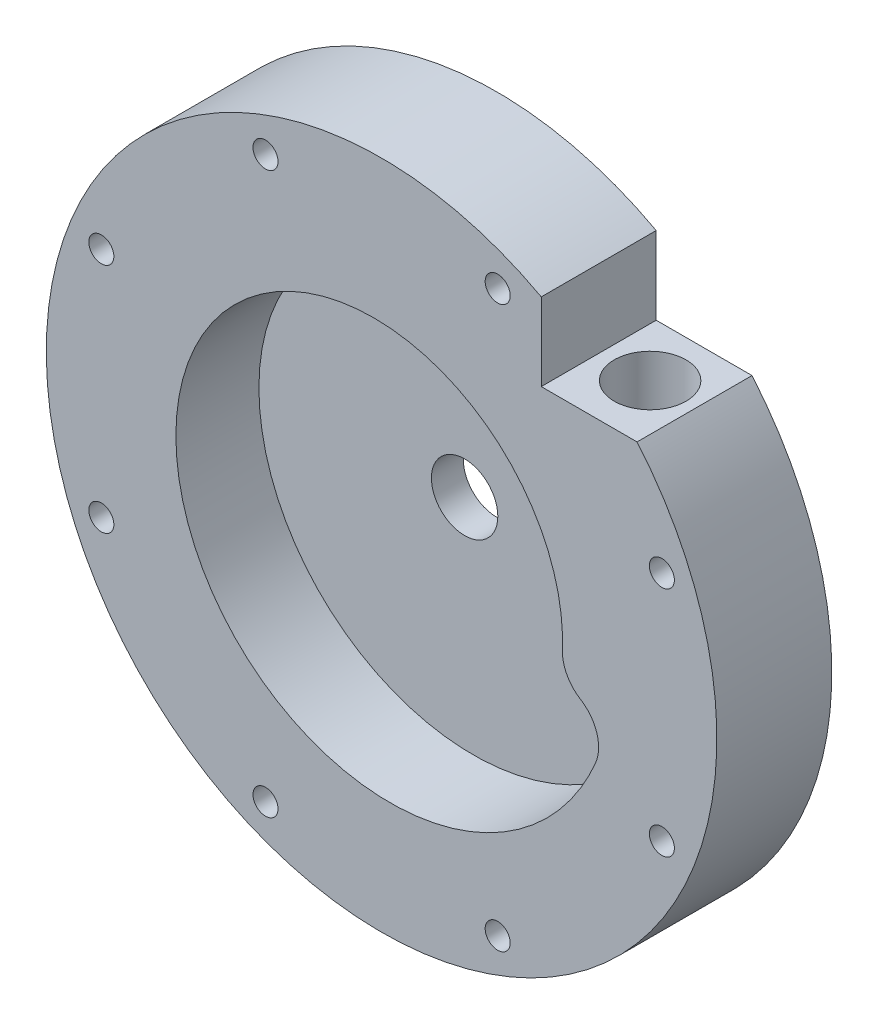
from build123d import *

# Parameters (mm, degrees)
SKETCH23_R            = 25.4
VOLUTE_CUT_DEPTH      = 17.51
SKETCH28_W            = 19.053968595
SKETCH28_H            = 15.450138368
OUTLET_HOLE_CUT_DEPTH = 23.86
OUTLET_HOLE_D         = 9.8044
OUTLET_HOLE_DEPTH     = 55.88
OUTLET_HOLE_TIP       = 2.945538927
OUTLET_NPT_D          = 14.2748
OUTLET_NPT_DEPTH      = 12.7
OUTLET_NPT_TIP        = 4.288582582
FASTENER_HOLES_D      = 4.9784
CIRPATTERN1_COUNT     = 8


with BuildPart() as part:
    # Sketch22 → Main Body (revolve)
    with BuildSketch(Plane(origin=(0, 0, 0), x_dir=(1, 0, 0), z_dir=(0, 1, 0))):
        Polygon((-25.4, 0), (-6.604, 0), (-6.604, 6.35), (-11.1125, 6.35), (-11.1125, 3.175), (-17.4625, 3.175), (-17.4625, 6.35), (-66.675, 6.35), (-66.675, -16.51), (-25.4, -16.51), align=None)
    revolve(axis=Axis((0, 0, 0), (0, 0, -1)))

    # Sketch23 → Volute Cut (cut, through all)
    with BuildSketch(Plane.XY):
        with BuildLine():
            ThreePointArc((42.554027377, -16.231646763), (42.805320101, -10.94498561), (39.552581276, -6.769865934))
            ThreePointArc((39.552581276, -6.769865934), (36.836858206, -3.87137787), (35.948703812, 0))
            add(Edge.make_bspline(
                [(35.948703812, 0), (35.9515816, 0.07538119), (35.957337916, 0.226162951), (35.964207937, 0.452426553), (35.969771157, 0.678783022), (35.978029534, 1.131847853), (35.980843708, 2.190601907), (35.920311441, 3.779931016), (35.747323363, 5.668216834), (35.489928088, 7.474298946), (35.141459932, 9.268877369), (34.702390603, 11.047358984), (34.17343386, 12.80516853), (33.555538624, 14.537761538), (32.849887572, 16.240636382), (32.057893687, 17.909346365), (31.181197352, 19.53951152), (30.221662701, 21.126830276), (29.181373626, 22.667090912), (28.062629225, 24.156182809), (26.867938753, 25.590107465), (25.60001603, 26.964989265), (24.261773335, 28.277085961), (22.856314773, 29.522798851), (21.386929147, 30.698682629), (19.85708232, 31.801454876), (18.270409111, 32.828005175), (16.630704717, 33.775403815), (14.941915703, 34.640910073), (13.208130556, 35.421980041), (11.43356985, 36.116273987), (9.622576022, 36.721663214), (7.779602801, 37.236236415), (5.909204301, 37.658305492), (4.016023818, 37.986410831), (2.104782347, 38.219326014), (0.180266852, 38.356061949), (-1.75268168, 38.395870413), (-3.689180377, 38.338246992), (-5.624316777, 38.182933409), (-7.553161251, 37.929919231), (-9.470779522, 37.579442948), (-11.37224525, 37.131992419), (-13.252652651, 36.588304682), (-15.107129112, 35.949365124), (-16.930847778, 35.216406011), (-18.719040078, 34.390904381), (-20.467008144, 33.474579298), (-22.170137115, 32.469388481), (-23.823907266, 31.377524301), (-25.42390596, 30.201409162), (-26.965839357, 28.943690275), (-28.445543888, 27.607233836), (-29.858997424, 26.195118613), (-31.202330147, 24.710628968), (-32.471835063, 23.157247319), (-33.663978152, 21.538646066), (-34.775408104, 19.858679), (-35.802965645, 18.121372202), (-36.743692396, 16.330914471), (-37.594839261, 14.491647299), (-38.353874308, 12.608054401), (-39.018490139, 10.68475085), (-39.586610697, 8.726471825), (-40.056397525, 6.738061006), (-40.426255434, 4.724458642), (-40.694837576, 2.690689328), (-40.861049894, 0.641849508), (-40.924054953, -1.416905249), (-40.883275123, -3.480373184), (-40.738395114, -5.543319447), (-40.489363842, -7.600489337), (-40.13639564, -9.646621653), (-39.679970776, -11.676462103), (-39.120835312, -13.684776759), (-38.460000265, -15.666365517), (-37.698740094, -17.61607551), (-36.838590511, -19.528814477), (-35.881345602, -21.399564006), (-34.829054288, -23.223392663), (-33.684016107, -24.995468936), (-32.44877635, -26.711073982), (-31.126120537, -28.365614138), (-29.719068263, -29.954633155), (-28.230866416, -31.473824138), (-26.664981791, -32.919041144), (-25.025093105, -34.286310417), (-23.315082441, -35.571841228), (-21.53902614, -36.772036288), (-19.701185153, -37.883501708), (-17.805994889, -38.903056478), (-15.85805457, -39.827741435), (-13.862116128, -40.654827709), (-11.823072667, -41.381824596), (-9.745946518, -42.006486871), (-7.635876912, -42.526821485), (-5.498107312, -42.941093656), (-3.337972426, -43.247832311), (-1.160884928, -43.445834888), (1.027678058, -43.534171454), (3.222188708, -43.512188152), (5.417082419, -43.379509955), (7.606771886, -43.136042707), (9.785661288, -42.781974466), (11.948160555, -42.317776118), (14.08869967, -41.74420128), (16.201742982, -41.062285471), (18.281803484, -40.273344558), (20.323457017, -39.378972487), (22.321356376, -38.381038284), (24.27024527, -37.281682345), (26.164972102, -36.083312015), (28.000503535, -34.788596469), (29.77193781, -33.400460899), (31.474517775, -31.92208003), (33.103643596, -30.356870964), (34.654885111, -28.708485383), (36.123993806, -26.980801118), (37.506914359, -25.17791311), (38.799795742, -23.304123775), (39.999001844, -21.363932809), (41.101121576, -19.362026441), (41.938186302, -17.641904891), (42.402189205, -16.588613759), (42.554027377, -16.231646763)],
                knots=[0, 0, 0, 0, 0.000879209, 0.001758645, 0.002638305, 0.003518191, 0.007039982, 0.014977213, 0.022047939, 0.029133237, 0.036233164, 0.043347773, 0.050477114, 0.057621232, 0.06478017, 0.071953969, 0.079142669, 0.086346306, 0.093564916, 0.100798534, 0.108047194, 0.115310927, 0.122589766, 0.12988374, 0.13719288, 0.144517215, 0.151856774, 0.159211583, 0.16658167, 0.173967063, 0.181367786, 0.188783866, 0.196215328, 0.203662198, 0.211124498, 0.218602253, 0.226095488, 0.233604225, 0.241128486, 0.248668296, 0.256223676, 0.263794648, 0.271381234, 0.278983456, 0.286601335, 0.294234891, 0.301884146, 0.309549121, 0.317229835, 0.324926308, 0.332638561, 0.340366614, 0.348110485, 0.355870195, 0.363645762, 0.371437205, 0.379244543, 0.387067795, 0.39490698, 0.402762115, 0.410633219, 0.41852031, 0.426423405, 0.434342523, 0.442277682, 0.450228898, 0.458196189, 0.466179572, 0.474179065, 0.482194684, 0.490226447, 0.498274369, 0.506338468, 0.514418761, 0.522515263, 0.530627991, 0.538756962, 0.546902191, 0.555063694, 0.563241488, 0.571435588, 0.57964601, 0.58787277, 0.596115883, 0.604375364, 0.61265123, 0.620943495, 0.629252175, 0.637577285, 0.64591884, 0.654276855, 0.662651345, 0.671042324, 0.679449808, 0.687873812, 0.696314349, 0.704771435, 0.713245083, 0.721735309, 0.730242127, 0.738765551, 0.747305595, 0.755862273, 0.7644356, 0.77302559, 0.781632256, 0.790255613, 0.798895674, 0.807552454, 0.816225965, 0.824916222, 0.833623239, 0.842347028, 0.851087604, 0.859844979, 0.868619169, 0.877410184, 0.88621804, 0.895042749, 0.903884325, 0.912742781, 0.921618129, 0.930510383, 0.935031581, 0.935031581, 0.935031581, 0.935031581], degree=3))
        make_face()
        Circle(SKETCH23_R, mode=Mode.SUBTRACT)
    extrude(amount=VOLUTE_CUT_DEPTH, mode=Mode.SUBTRACT)

    # Sketch28 → Outlet Hole Cut (cut, through all)
    with BuildSketch(Plane.XY.offset(16.51)):
        with Locations((41.276984298, 50.905069184)):
            Rectangle(SKETCH28_W, SKETCH28_H)
    extrude(amount=-OUTLET_HOLE_CUT_DEPTH, mode=Mode.SUBTRACT)

    # Outlet Hole
    with Locations(Plane(origin=(41.529, 43.18, 4.637659), x_dir=(0, 0, 1), z_dir=(0, 1, 0))):
        with Locations((0, 0)):
            Hole(OUTLET_HOLE_D / 2, depth=OUTLET_HOLE_DEPTH)
            with Locations((0, 0, -(OUTLET_HOLE_DEPTH + OUTLET_HOLE_TIP / 2))):  # 118° drill point
                Cone(0, OUTLET_HOLE_D / 2, OUTLET_HOLE_TIP, mode=Mode.SUBTRACT)

    # Outlet NPT
    with Locations(Plane(origin=(41.529, 43.18, 4.637659), x_dir=(0, 0, 1), z_dir=(0, 1, 0))):
        with Locations((0, 0)):
            Hole(OUTLET_NPT_D / 2, depth=OUTLET_NPT_DEPTH)
            with Locations((0, 0, -(OUTLET_NPT_DEPTH + OUTLET_NPT_TIP / 2))):  # 118° drill point
                Cone(0, OUTLET_NPT_D / 2, OUTLET_NPT_TIP, mode=Mode.SUBTRACT)

    # Fastener Holes (through all)
    with Locations(Plane(origin=(55.733032799, -23.085378057, 16.51), x_dir=(1, 0, 0), z_dir=(0, 0, 1))):
        with Locations((0, 0)):
            fastener_holes = Hole(FASTENER_HOLES_D / 2)

    # CirPattern1: Fastener Holes ×8 about axis
    cirpattern1_axis = Axis((0, 0, 0), (0, 0, 1))
    for i in range(1, CIRPATTERN1_COUNT):
        add(fastener_holes.rotate(cirpattern1_axis, i * 360 / CIRPATTERN1_COUNT), mode=Mode.SUBTRACT)


solid = part.part
